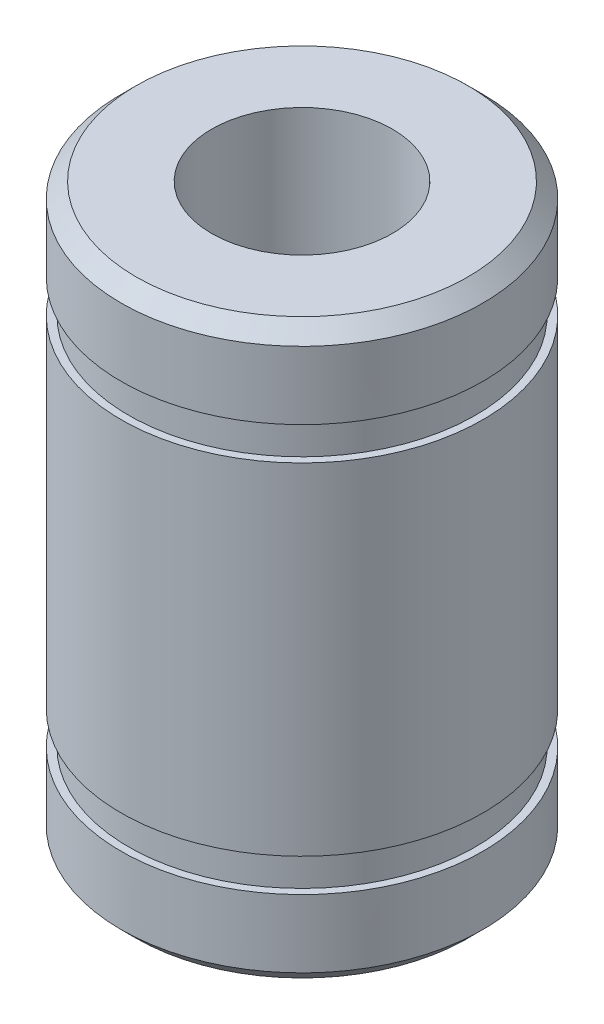
from build123d import *

# Parameters (mm, degrees)
CHAMFER1_SIZE = 0.5


with BuildPart() as part:
    # Sketch1 → Revolve1 (revolve)
    with BuildSketch(Plane.XY):
        Polygon((3, 0), (3, 9.5), (6, 9.5), (6, 6.75), (5.75, 6.75), (5.75, 5.65), (6, 5.65), (6, 0), align=None)
    revolve(axis=Axis((0, 0, 0), (0, 1, 0)))

    # Chamfer1
    chamfer1_edges = [part.edges().sort_by_distance(p)[0] for p in [
        (-6, 9.5, 0),
    ]]
    chamfer(chamfer1_edges, length=CHAMFER1_SIZE)

    # Mirror1: part across plane


with BuildPart() as part_1:
    add(part.part)
    add(part.part.mirror(Plane(origin=(6, 0, 0), x_dir=(0, 0, 1), z_dir=(0, -1, 0))))


solid = part_1.part
